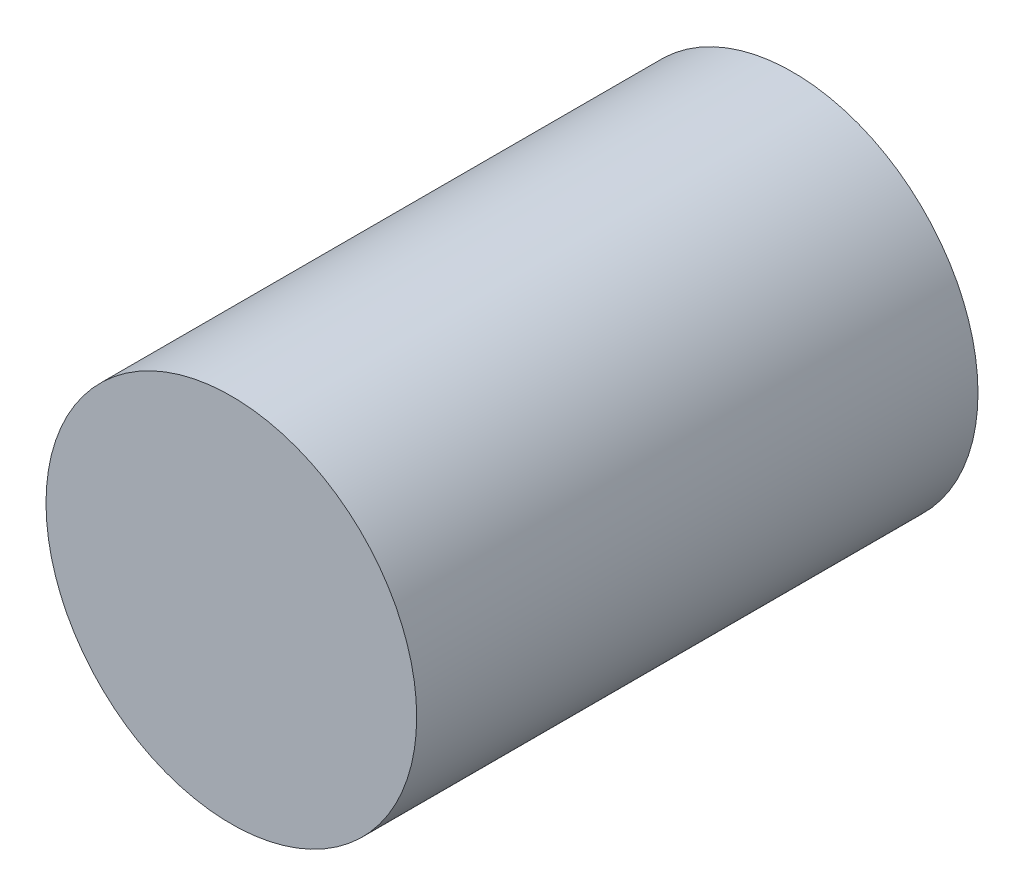
from build123d import *

# Parameters (mm, degrees)
SKETCH1_R           = 87.5
BOSS_EXTRUDE1_DEPTH = 132.5
BOSS_EXTRUDE2_START = -132.5
SKETCH1_3_R         = 87.5
BOSS_EXTRUDE2_DEPTH = 132.5


with BuildPart() as part:
    # Sketch1 → Boss-Extrude1 (new body)
    with BuildSketch(Plane.XY):
        Circle(SKETCH1_R)
    extrude(amount=BOSS_EXTRUDE1_DEPTH)

    # Sketch1_3 → Boss-Extrude2 (add)
    with BuildSketch(Plane.XY.offset(BOSS_EXTRUDE2_START)):
        Circle(SKETCH1_3_R)
    extrude(amount=BOSS_EXTRUDE2_DEPTH)


solid = part.part
